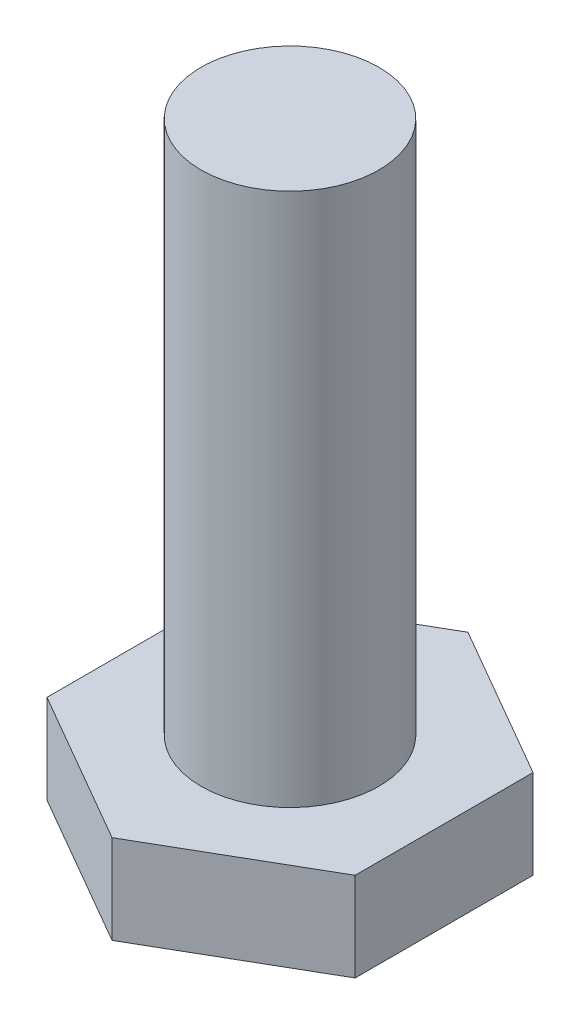
from build123d import *

# Parameters (mm, degrees)
SKETCH1_R           = 1
BOSS_EXTRUDE1_DEPTH = 0.5
SKETCH2_R           = 0.5
BOSS_EXTRUDE2_DEPTH = 3
SKETCH3_OUTSIDE_W   = 4.9
SKETCH3_OUTSIDE_H   = 4.9
CUT_EXTRUDE1_DEPTH  = 10


with BuildPart() as part:
    # Sketch1 → Boss-Extrude1 (new body)
    with BuildSketch(Plane(origin=(0, 0, 0), x_dir=(1, 0, 0), z_dir=(0, 1, 0))):
        Circle(SKETCH1_R)
    extrude(amount=BOSS_EXTRUDE1_DEPTH)

    # Sketch2 → Boss-Extrude2 (add)
    with BuildSketch(Plane(origin=(0, 0.5, 0), x_dir=(1, 0, 0), z_dir=(0, 1, 0))):
        Circle(SKETCH2_R)
    extrude(amount=BOSS_EXTRUDE2_DEPTH)

    # Sketch3 outside → Cut-Extrude1 (cut)
    with BuildSketch(Plane(origin=(0, 0, 0), x_dir=(-1, 0, 0), z_dir=(0, -1, 0))):
        Rectangle(SKETCH3_OUTSIDE_W, SKETCH3_OUTSIDE_H)
        Polygon((0, 1), (0.866025404, 0.5), (0.866025404, -0.5), (0, -1), (-0.866025404, -0.5), (-0.866025404, 0.5), align=None, mode=Mode.SUBTRACT)
    extrude(amount=-CUT_EXTRUDE1_DEPTH, mode=Mode.SUBTRACT)


solid = part.part
